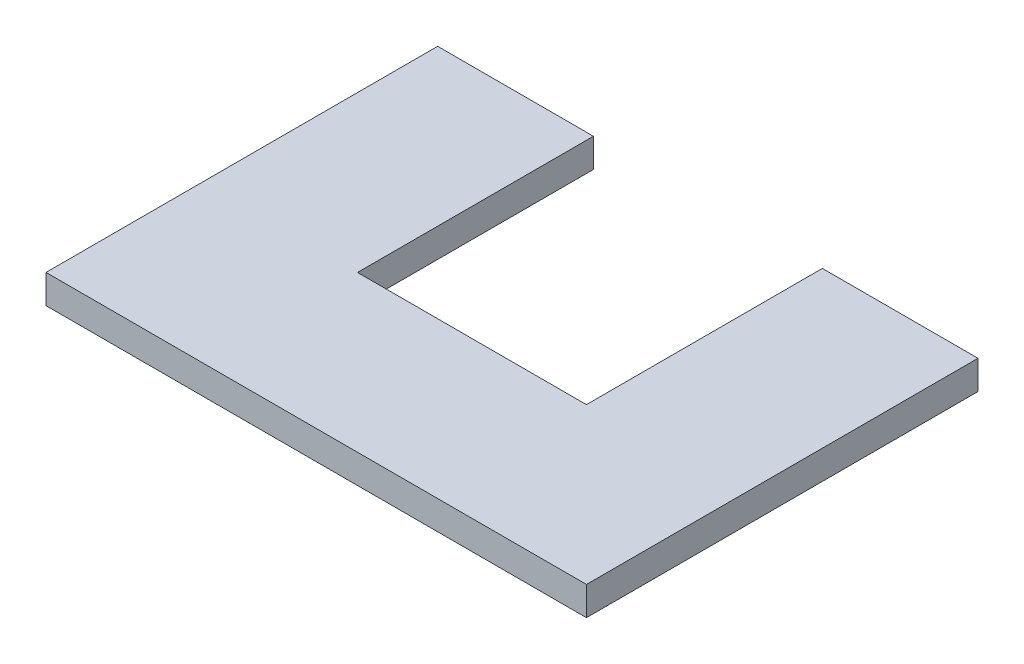
from build123d import *

# Parameters (mm, degrees)
BOSS_EXTRUDE1_DEPTH = 3.175


with BuildPart() as part:
    # Sketch2 → Boss-Extrude1 (new body)
    with BuildSketch(Plane(origin=(0, 0, 0), x_dir=(1, 0, 0), z_dir=(0, 1, 0))):
        Polygon((-8.345674947, 26.083074024), (8.824135378, 26.083074024), (8.824135378, 0.16888316), (8.824135378, 0.079975058), (33.965837388, 0.079975058), (34.05638807, 0.079975058), (34.05638807, 26.083074024), (51.210423078, 26.083074024), (51.220712183, -17.081265506), (-8.345674947, -17.081265506), align=None)
    extrude(amount=BOSS_EXTRUDE1_DEPTH)


solid = part.part
